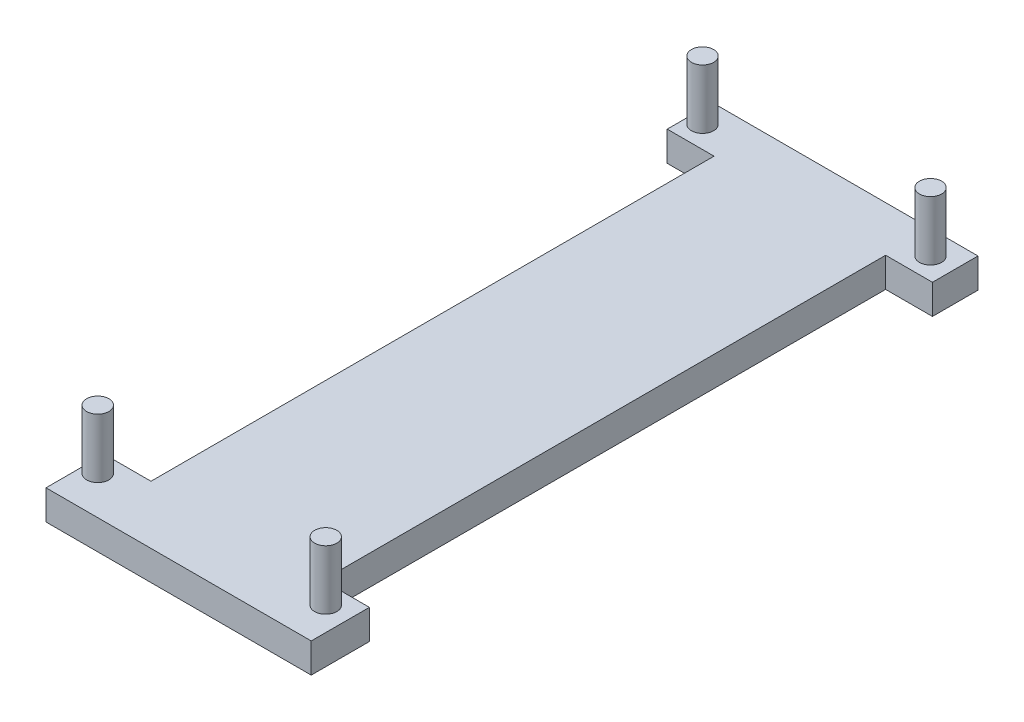
from build123d import *

# Parameters (mm, degrees)
SKETCH1_W           = 17.9
SKETCH1_H           = 45
BOSS_EXTRUDE1_DEPTH = 2
SKETCH2_R           = 0.75
BOSS_EXTRUDE2_DEPTH = 4
SKETCH4_W           = 3.16
SKETCH4_H           = 38
CUT_EXTRUDE1_DEPTH  = 3.5


with BuildPart() as part:
    # Sketch1 → Boss-Extrude1 (new body)
    with BuildSketch(Plane(origin=(0, 0, 0), x_dir=(1, 0, 0), z_dir=(0, 1, 0))):
        with Locations((8.95, 22.5)):
            Rectangle(SKETCH1_W, SKETCH1_H)
    extrude(amount=BOSS_EXTRUDE1_DEPTH)

    # Sketch2 → Boss-Extrude2 (add)
    with BuildSketch(Plane(origin=(0, 2, 0), x_dir=(1, 0, 0), z_dir=(0, 1, 0))):
        with Locations((0.913071853, 43.396593807)):
            Circle(SKETCH2_R)
        with Locations((16.300481816, 43.396593807)):
            Circle(SKETCH2_R)
        with Locations((16.300481816, 2.58)):
            Circle(SKETCH2_R)
        with Locations((0.913071853, 2.58)):
            Circle(SKETCH2_R)
    extrude(amount=BOSS_EXTRUDE2_DEPTH)

    # Sketch4 → Cut-Extrude1 (cut)
    with BuildSketch(Plane(origin=(0, 2, 0), x_dir=(1, 0, 0), z_dir=(0, 1, 0))):
        with Locations((1.58, 22.925686587)):
            Rectangle(SKETCH4_W, SKETCH4_H)
        with Locations((16.32, 22.925686587)):
            Rectangle(SKETCH4_W, SKETCH4_H)
    extrude(amount=-CUT_EXTRUDE1_DEPTH, mode=Mode.SUBTRACT)


solid = part.part
